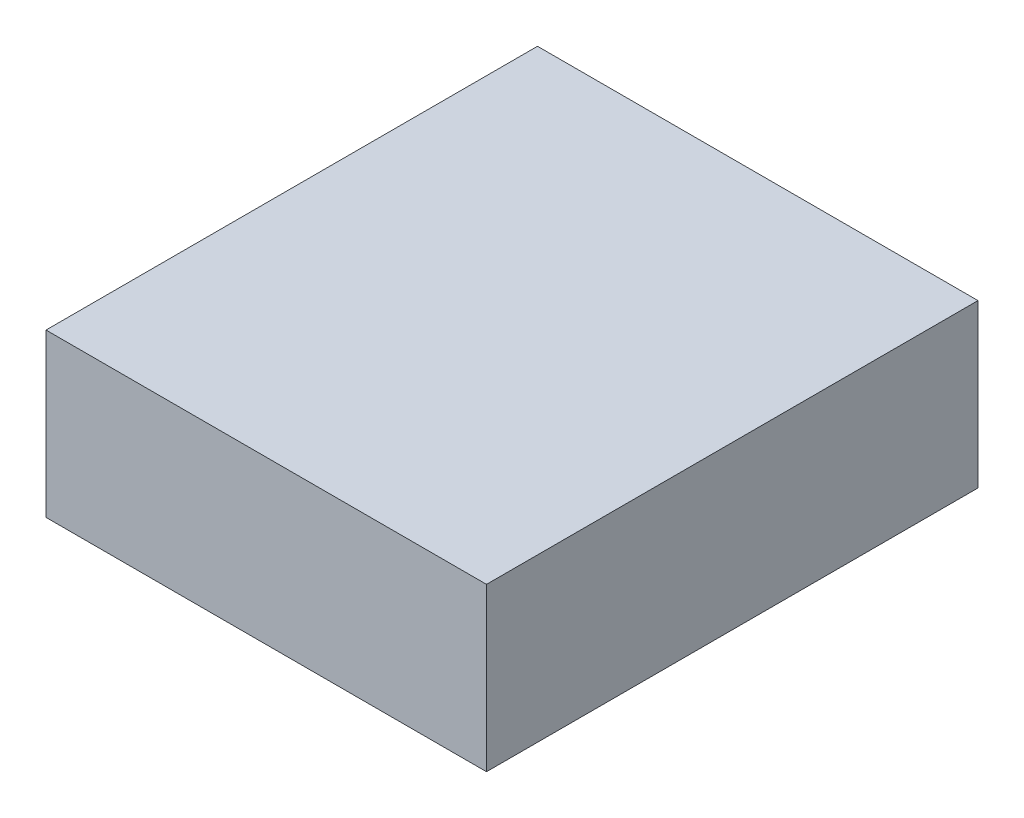
from build123d import *

# Parameters (mm, degrees)
SKETCH1_W           = 3.8
SKETCH1_H           = 4.24
BOSS_EXTRUDE1_DEPTH = 1.4


with BuildPart() as part:
    # Sketch1 → Boss-Extrude1 (new body)
    with BuildSketch(Plane(origin=(0, 0, 0), x_dir=(1, 0, 0), z_dir=(0, 1, 0))):
        with Locations((-3.067664042, 0.744561151)):
            Rectangle(SKETCH1_W, SKETCH1_H)
    extrude(amount=BOSS_EXTRUDE1_DEPTH)


solid = part.part
